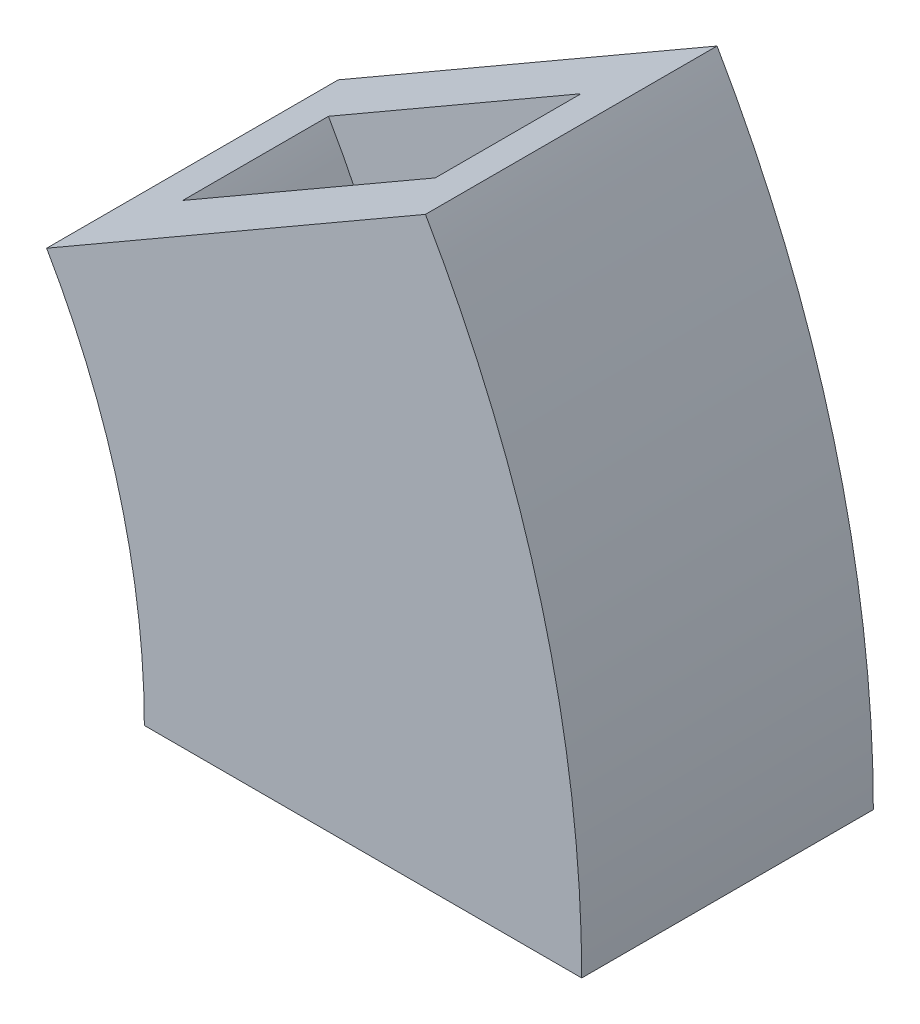
from build123d import *

# Parameters (mm, degrees)
BOSS_EXTRUDE1_DEPTH   = 10
BOSS_EXTRUDE1_2_DEPTH = 10
BOSS_EXTRUDE2_DEPTH   = 5
BOSS_EXTRUDE3_DEPTH   = 5


with BuildPart() as part:
    # Sketch1 → Boss-Extrude1 (new body)
    with BuildSketch(Plane.XY):
        with BuildLine():
            ThreePointArc((36.063682392, 40.248355648), (41.058703517, 28.189307903), (42.762412203, 15.248355648))
            Line((42.762412203, 15.248355648), (47.762412203, 15.248355648))
            ThreePointArc((47.762412203, 15.248355648), (45.888332649, 29.483403128), (40.393809411, 42.748355648))
            Line((40.393809411, 42.748355648), (36.063682392, 40.248355648))
        make_face()
    extrude(amount=BOSS_EXTRUDE1_DEPTH)



with BuildPart() as body_2:
    # Sketch1 → Boss-Extrude1 2 (new body)
    with BuildSketch(Plane.XY):
        with BuildLine():
            ThreePointArc((57.714317487, 52.748355648), (65.206849175, 34.65978403), (67.762412203, 15.248355648))
            Line((67.762412203, 15.248355648), (72.762412203, 15.248355648))
            ThreePointArc((72.762412203, 15.248355648), (70.036478306, 35.953879256), (62.044444506, 55.248355648))
            Line((62.044444506, 55.248355648), (57.714317487, 52.748355648))
        make_face()
    extrude(amount=BOSS_EXTRUDE1_2_DEPTH)


with BuildPart() as part_1:
    add(part.part)

    add(body_2.part)  # Boss-Extrude2 merges body 2
    # Sketch2 → Boss-Extrude2 (add)
    with BuildSketch(Plane.XY.offset(10)):
        with BuildLine():
            Line((36.063682392, 40.248355648), (62.044444506, 55.248355648))
            ThreePointArc((62.044444506, 55.248355648), (70.036478306, 35.953879256), (72.762412203, 15.248355648))
            Line((72.762412203, 15.248355648), (42.762412203, 15.248355648))
            ThreePointArc((42.762412203, 15.248355648), (41.058703517, 28.189307903), (36.063682392, 40.248355648))
        make_face()
    extrude(amount=BOSS_EXTRUDE2_DEPTH)

    # Sketch3 → Boss-Extrude3 (add)
    with BuildSketch(Plane(origin=(0, 0, 0), x_dir=(-1, 0, 0), z_dir=(0, 0, -1))):
        with BuildLine():
            Line((-36.063682392, 40.248355648), (-62.044444506, 55.248355648))
            ThreePointArc((-62.044444506, 55.248355648), (-70.036478306, 35.953879256), (-72.762412203, 15.248355648))
            Line((-72.762412203, 15.248355648), (-42.762412203, 15.248355648))
            ThreePointArc((-42.762412203, 15.248355648), (-41.058703517, 28.189307903), (-36.063682392, 40.248355648))
        make_face()
    extrude(amount=BOSS_EXTRUDE3_DEPTH)


solid = part_1.part
